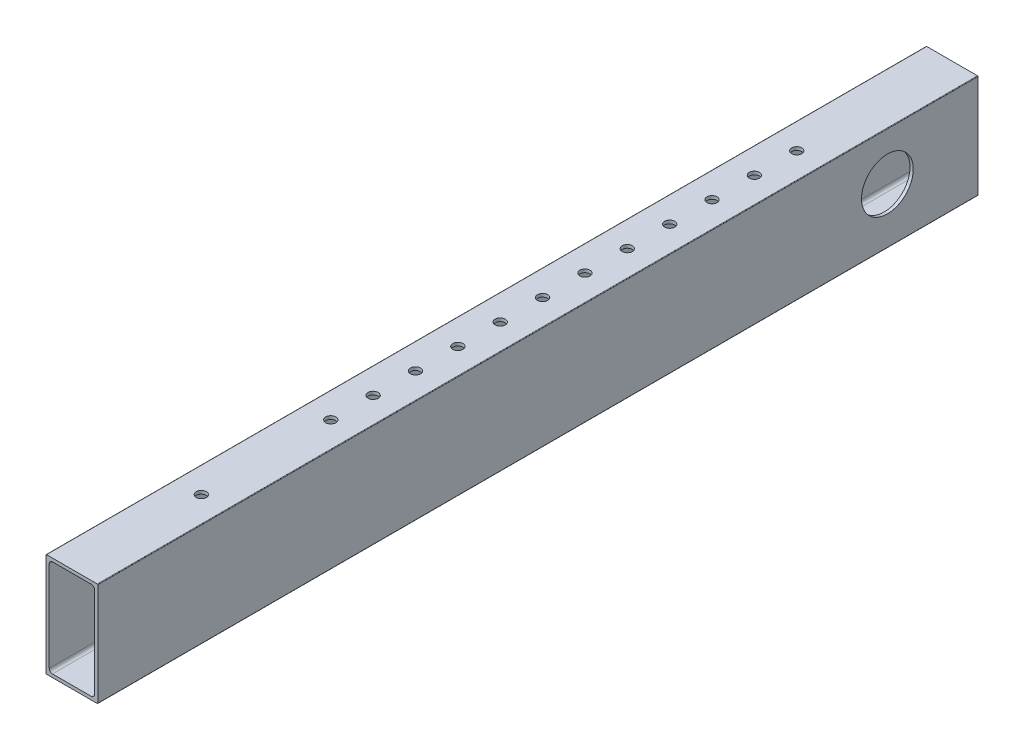
from build123d import *

# Parameters (mm, degrees)
BOSS_EXTRUDE1_DEPTH      = 25.4
BOSS_EXTRUDE1_DEPTH_BACK = 406.4
SKETCH2_R                = 12.7
CUT_EXTRUDE1_DEPTH       = 25.4
SKETCH3_R                = 2.4892
CUT_EXTRUDE2_DEPTH       = 1
CUT_EXTRUDE2_DEPTH_BACK  = 51.8


with BuildPart() as part:
    # Sketch1 → Boss-Extrude1 (new body, two sides)
    with BuildSketch(Plane(origin=(0, 0, 0), x_dir=(-1, 0, 0), z_dir=(0, 0, -1))) as boss_extrude1_sk:
        with BuildLine():
            Line((-12.7, 25.146), (-12.7, -25.146))
            ThreePointArc((-12.7, -25.146), (-12.625605122, -25.325605122), (-12.446, -25.4))
            Line((-12.446, -25.4), (12.446, -25.4))
            ThreePointArc((12.446, -25.4), (12.625605122, -25.325605122), (12.7, -25.146))
            Line((12.7, -25.146), (12.7, 25.146))
            ThreePointArc((12.7, 25.146), (12.625605122, 25.325605122), (12.446, 25.4))
            Line((12.446, 25.4), (-12.446, 25.4))
            ThreePointArc((-12.446, 25.4), (-12.625605122, 25.325605122), (-12.7, 25.146))
        make_face()
        with BuildLine():
            Line((-11.1125, -22.225), (-11.1125, 22.225))
            ThreePointArc((-11.1125, 22.225), (-10.647532015, 23.347532015), (-9.525, 23.8125))
            Line((-9.525, 23.8125), (9.525, 23.8125))
            ThreePointArc((9.525, 23.8125), (10.647532015, 23.347532015), (11.1125, 22.225))
            Line((11.1125, 22.225), (11.1125, -22.225))
            ThreePointArc((11.1125, -22.225), (10.647532015, -23.347532015), (9.525, -23.8125))
            Line((9.525, -23.8125), (-9.525, -23.8125))
            ThreePointArc((-9.525, -23.8125), (-10.647532015, -23.347532015), (-11.1125, -22.225))
        make_face(mode=Mode.SUBTRACT)
    extrude(amount=BOSS_EXTRUDE1_DEPTH)
    extrude(boss_extrude1_sk.sketch, amount=-BOSS_EXTRUDE1_DEPTH_BACK)

    # Sketch2 → Cut-Extrude1 (cut)
    with BuildSketch(Plane.ZY.offset(12.7)):
        with Locations((19.05, 1.778)):
            Circle(SKETCH2_R)
    extrude(amount=-CUT_EXTRUDE1_DEPTH, mode=Mode.SUBTRACT)

    # Sketch3 → Cut-Extrude2 (cut, two sides)
    with BuildSketch(Plane.XZ.offset(25.4)) as cut_extrude2_sk:
        with Locations((0, 50.8)):
            Circle(SKETCH3_R)
        with Locations((0, 71.581818182)):
            Circle(SKETCH3_R)
        with Locations((0, 92.363636364)):
            Circle(SKETCH3_R)
        with Locations((0, 113.145454545)):
            Circle(SKETCH3_R)
        with Locations((0, 133.927272727)):
            Circle(SKETCH3_R)
        with Locations((0, 154.709090909)):
            Circle(SKETCH3_R)
        with Locations((0, 175.490909091)):
            Circle(SKETCH3_R)
        with Locations((0, 196.272727273)):
            Circle(SKETCH3_R)
        with Locations((0, 217.054545455)):
            Circle(SKETCH3_R)
        with Locations((0, 237.836363636)):
            Circle(SKETCH3_R)
        with Locations((0, 258.618181818)):
            Circle(SKETCH3_R)
        with Locations((0, 342.9)):
            Circle(SKETCH3_R)
        with Locations((0, 279.4)):
            Circle(SKETCH3_R)
    extrude(amount=CUT_EXTRUDE2_DEPTH, mode=Mode.SUBTRACT)
    extrude(cut_extrude2_sk.sketch, amount=-CUT_EXTRUDE2_DEPTH_BACK, mode=Mode.SUBTRACT)


solid = part.part
